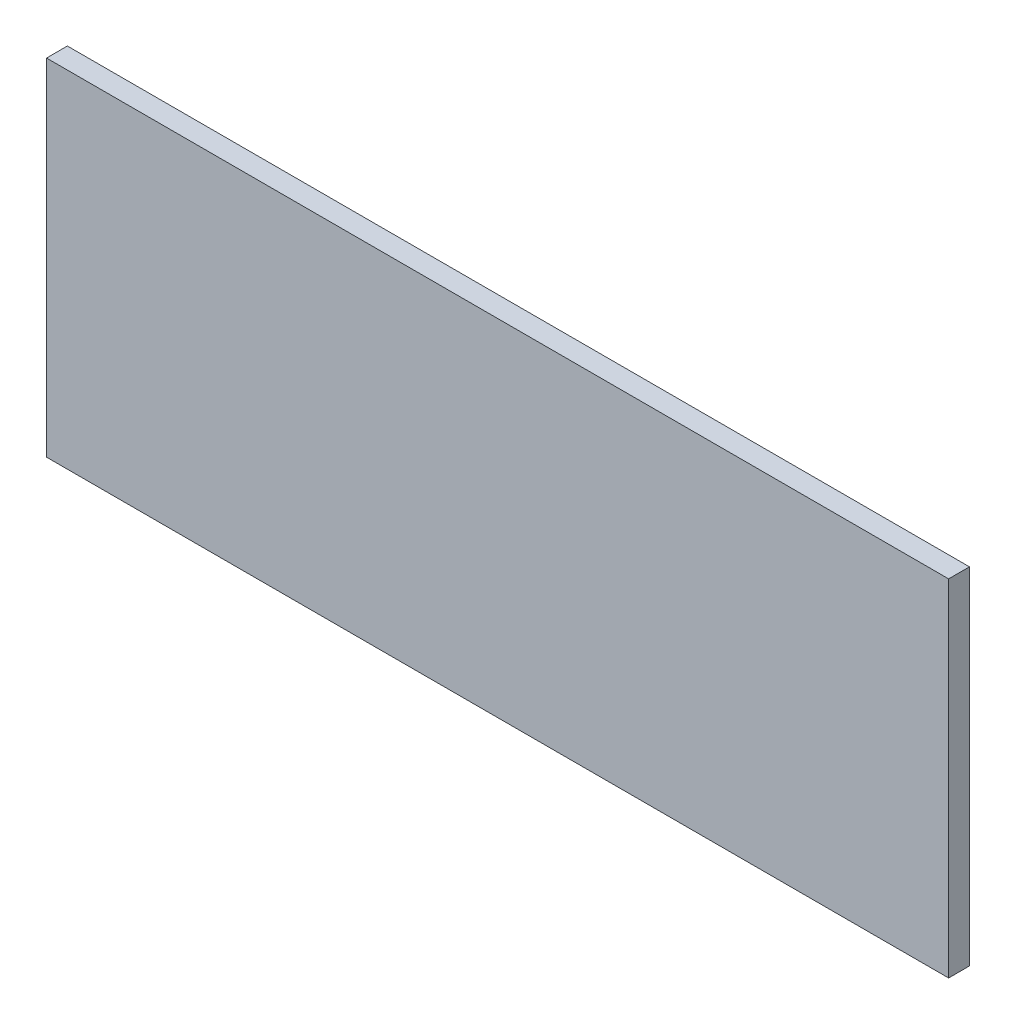
from build123d import *

# Parameters (mm, degrees)
SKETCH1_W           = 779
SKETCH1_H           = 298.5
BOSS_EXTRUDE1_DEPTH = 18


with BuildPart() as part:
    # Sketch1 → Boss-Extrude1 (new body)
    with BuildSketch(Plane.XY):
        Rectangle(SKETCH1_W, SKETCH1_H)
    extrude(amount=BOSS_EXTRUDE1_DEPTH)


solid = part.part
